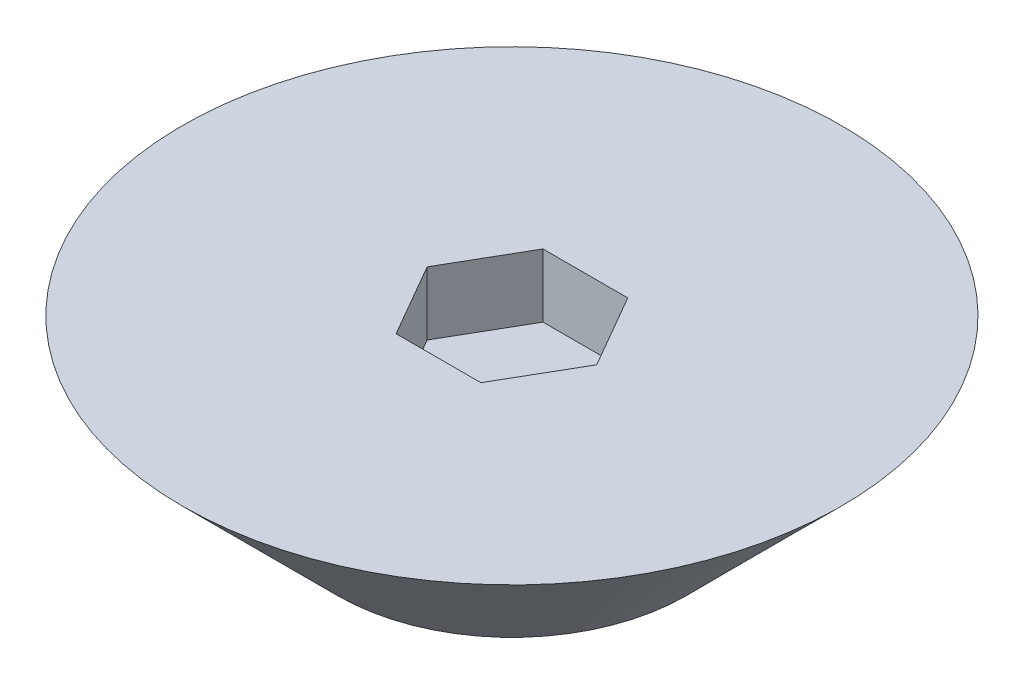
from build123d import *

# Parameters (mm, degrees)
SKETCH5_R          = 2.75
SKETCH4_R          = 5.2
CUT_EXTRUDE1_DEPTH = 1


with BuildPart() as part:
    # Sketch5 → Loft1 section 0
    with BuildSketch(Plane(origin=(0, 0, 0), x_dir=(1, 0, 0), z_dir=(0, 1, 0))):
        Circle(SKETCH5_R)
    # Sketch4 → Loft1 section 1
    with BuildSketch(Plane(origin=(0, 2.45, 0), x_dir=(1, 0, 0), z_dir=(0, 1, 0))):
        Circle(SKETCH4_R)
    loft()

    # Sketch6 → Cut-Extrude1 (cut)
    with BuildSketch(Plane(origin=(0, 2.45, 0), x_dir=(1, 0, 0), z_dir=(0, 1, 0))):
        Polygon((1.337999459, 0), (0.66899973, 1.158741522), (-0.66899973, 1.158741522), (-1.337999459, 0), (-0.66899973, -1.158741522), (0.66899973, -1.158741522), align=None)
    extrude(amount=-CUT_EXTRUDE1_DEPTH, mode=Mode.SUBTRACT)


solid = part.part
